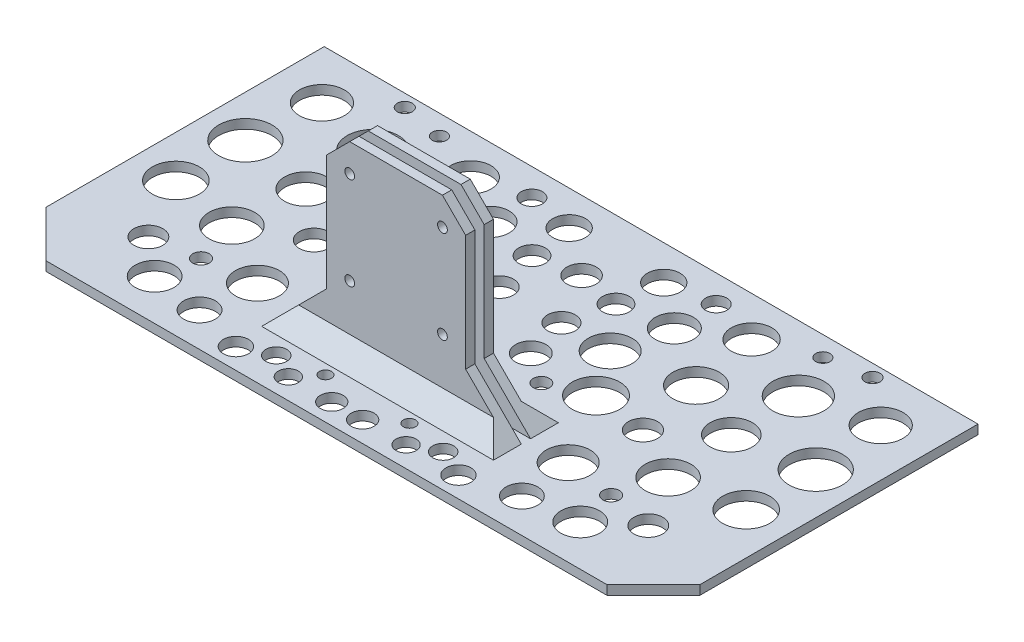
from build123d import *

# Parameters (mm, degrees)
SKETCH1_W           = 141
SKETCH1_H           = 70
BOSS_EXTRUDE1_DEPTH = 2
SKETCH2_W           = 30
SKETCH2_H           = 2
BOSS_EXTRUDE2_DEPTH = 40
SKETCH3_R           = 1.05
CUT_EXTRUDE1_DEPTH  = 20
CHAMFER1_SIZE       = 5
CHAMFER2_SIZE       = 10
CHAMFER3_SIZE       = 4
CHAMFER4_SIZE       = 10
SKETCH4_R           = 3.175
CUT_EXTRUDE2_DEPTH  = 10
SKETCH5_R           = 4.974636633
SKETCH5_R_2         = 3.146236459
SKETCH5_R_3         = 4.54576988
SKETCH5_R_4         = 5.519543083
SKETCH5_R_5         = 4.37453593
SKETCH5_R_6         = 4.123519833
SKETCH5_R_7         = 4.733675758
SKETCH5_R_8         = 5.109952542
SKETCH5_R_9         = 4.930902715
SKETCH5_R_10        = 3.1185767
SKETCH5_R_11        = 4.186079964
SKETCH5_R_12        = 3.423196992
SKETCH5_R_13        = 5.083908884
SKETCH5_R_14        = 5.746414823
SKETCH5_R_15        = 4.82911997
SKETCH5_R_16        = 1.618250018
SKETCH5_R_17        = 1.536391082
SKETCH5_R_18        = 2.291759317
SKETCH5_R_19        = 3.534495501
SKETCH5_R_20        = 2.885901018
SKETCH5_R_21        = 2.983748602
SKETCH5_R_22        = 3.273704374
SKETCH5_R_23        = 1.749106038
SKETCH5_R_24        = 1.76916029
SKETCH5_R_25        = 2.701911231
SKETCH5_R_26        = 2.165520053
SKETCH5_R_27        = 2.467098103
SKETCH5_R_28        = 1.303971465
SKETCH5_R_29        = 2.25029129
CUT_EXTRUDE3_DEPTH  = 10


with BuildPart() as part:
    # Sketch1 → Boss-Extrude1 (new body)
    with BuildSketch(Plane(origin=(0, 0, 0), x_dir=(1, 0, 0), z_dir=(0, 1, 0))):
        Rectangle(SKETCH1_W, SKETCH1_H)
    extrude(amount=BOSS_EXTRUDE1_DEPTH)

    # Sketch2 → Boss-Extrude2 (add)
    with BuildSketch(Plane(origin=(0, 2, 0), x_dir=(1, 0, 0), z_dir=(0, 1, 0))):
        with Locations((0, -15)):
            Rectangle(SKETCH2_W, SKETCH2_H)
        with Locations((0, -19)):
            Rectangle(SKETCH2_W, SKETCH2_H)
    extrude(amount=BOSS_EXTRUDE2_DEPTH)

    # Sketch3 → Cut-Extrude1 (cut)
    with BuildSketch(Plane.XY.offset(20)):
        with Locations((-10, 16)):
            Circle(SKETCH3_R)
        with Locations((-10, 36)):
            Circle(SKETCH3_R)
        with Locations((10, 36)):
            Circle(SKETCH3_R)
        with Locations((10, 16)):
            Circle(SKETCH3_R)
    extrude(amount=-CUT_EXTRUDE1_DEPTH, mode=Mode.SUBTRACT)

    # Chamfer1
    chamfer1_edges = [part.edges().sort_by_distance(p)[0] for p in [
        (-15, 42, 15),
        (15, 42, 15),
        (-15, 42, 19),
        (15, 42, 19),
    ]]
    chamfer(chamfer1_edges, length=CHAMFER1_SIZE)

    # Chamfer2
    chamfer2_edges = [part.edges().sort_by_distance(p)[0] for p in [
        (-15, 2, 15),
        (15, 2, 15),
        (-15, 2, 19),
        (15, 2, 19),
    ]]
    chamfer(chamfer2_edges, length=CHAMFER2_SIZE)

    # Chamfer3
    chamfer3_edges = [part.edges().sort_by_distance(p)[0] for p in [
        (0, 2, 14),
        (0, 2, 20),
    ]]
    chamfer(chamfer3_edges, length=CHAMFER3_SIZE)

    # Chamfer4
    chamfer4_edges = [part.edges().sort_by_distance(p)[0] for p in [
        (70.5, 1, 35),
        (-70.5, 1, 35),
    ]]
    chamfer(chamfer4_edges, length=CHAMFER4_SIZE)

    # Sketch4 → Cut-Extrude2 (cut)
    with BuildSketch(Plane(origin=(0, 2, 0), x_dir=(1, 0, 0), z_dir=(0, 1, 0))):
        with Locations((0, 20)):
            Circle(SKETCH4_R)
    extrude(amount=-CUT_EXTRUDE2_DEPTH, mode=Mode.SUBTRACT)

    # Sketch5 → Cut-Extrude3 (cut)
    with BuildSketch(Plane(origin=(0, 2, 0), x_dir=(1, 0, 0), z_dir=(0, 1, 0))):
        with Locations((-32.885567752, 11.811746645)):
            Circle(SKETCH5_R)
        with Locations((-35.487274061, -2.237467426)):
            Circle(SKETCH5_R_2)
        with Locations((-45.894099299, 6.400197521)):
            Circle(SKETCH5_R_3)
        with Locations((-45.894099299, 20.865684602)):
            Circle(SKETCH5_R_4)
        with Locations((-30.283861442, 26.385227685)):
            Circle(SKETCH5_R_5)
        with Locations((-19.877036204, 20.137206835)):
            Circle(SKETCH5_R_6)
        with Locations((-17.171261642, 9.001903831)):
            Circle(SKETCH5_R_7)
        with Locations((-24.000556037, -0.884580145)):
            Circle(SKETCH5_R_8)
        with Locations((-33.509977266, -16.39074975)):
            Circle(SKETCH5_R_7)
        with Locations((-47.038850075, -8.377494316)):
            Circle(SKETCH5_R_9)
        with Locations((-53.907354732, -19.512797321)):
            Circle(SKETCH5_R_10)
        with Locations((-45.894099299, -26.173165473)):
            Circle(SKETCH5_R_11)
        with Locations((-34.758796294, -27.630121007)):
            Circle(SKETCH5_R_12)
        with Locations((-61.504337156, -5.994532687)):
            Circle(SKETCH5_R_13)
        with Locations((-61.504337156, 9.001903831)):
            Circle(SKETCH5_R_14)
        with Locations((-60.255518127, 24.260726668)):
            Circle(SKETCH5_R_15)
        with Locations((-50.439869179, 32.313192364)):
            Circle(SKETCH5_R_16)
        with Locations((-41.348329419, 30.694942345)):
            Circle(SKETCH5_R_17)
        with Locations((-19.877036204, 29.158551263)):
            Circle(SKETCH5_R_18)
        with Locations((-10.198688733, 27.526052754)):
            Circle(SKETCH5_R_19)
        with Locations((-9.053937957, 18.368046545)):
            Circle(SKETCH5_R_20)
        with Locations((-6.664193232, 9.001903831)):
            Circle(SKETCH5_R_21)
        with Locations((-9.053937957, 0)):
            Circle(SKETCH5_R_22)
        with Locations((-15.753516372, -4.422900726)):
            Circle(SKETCH5_R_23)
        with Locations((-44.229007261, -17.847705283)):
            Circle(SKETCH5_R_24)
        with Locations((-24.000556037, -30.544032073)):
            Circle(SKETCH5_R_25)
        with Locations((-12.69632679, -30.544032073)):
            Circle(SKETCH5_R_26)
        with Locations((-3.330184076, -30.544032073)):
            Circle(SKETCH5_R_27)
        with Locations((-9.053937957, -26.173165473)):
            Circle(SKETCH5_R_28)
        with Locations((-18.003807661, -27.842120842)):
            Circle(SKETCH5_R_29)
    cut_extrude3 = extrude(amount=-CUT_EXTRUDE3_DEPTH, mode=Mode.SUBTRACT)

    # Mirror1: Cut-Extrude3 across plane
    add(cut_extrude3.mirror(Plane(origin=(0, 0, 0), x_dir=(0, 0, 1), z_dir=(1, 0, 0))), mode=Mode.SUBTRACT)


solid = part.part
